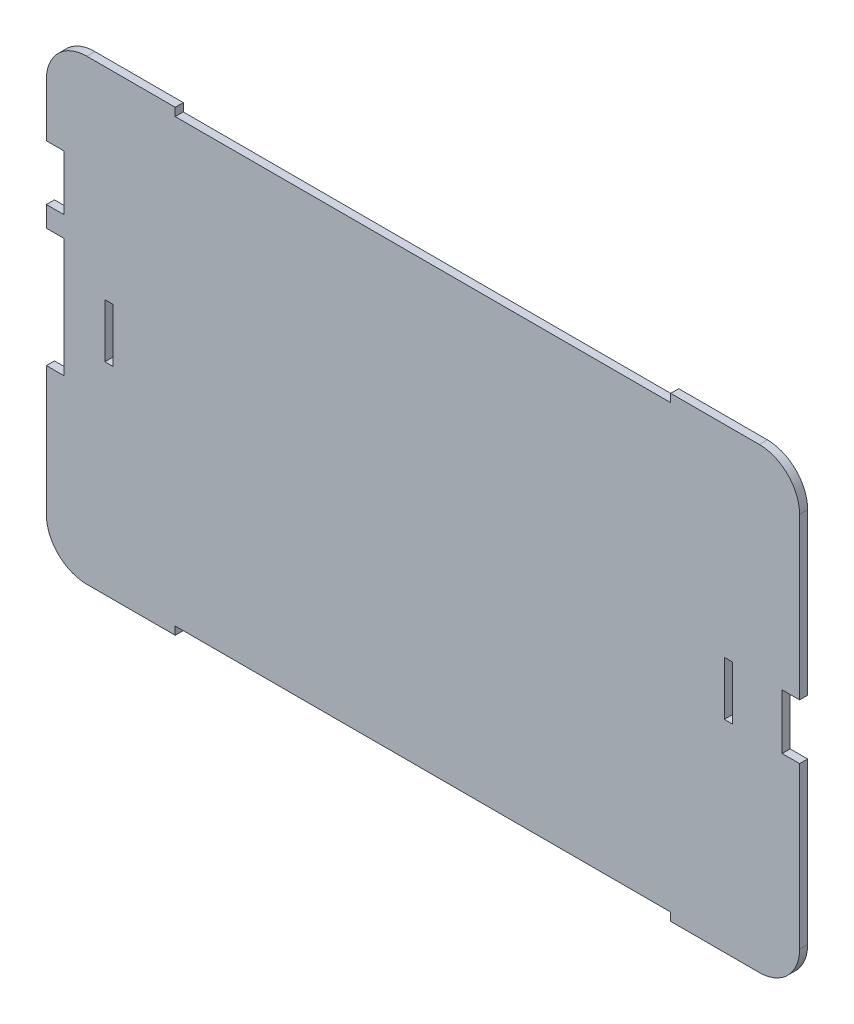
from build123d import *

# Parameters (mm, degrees)
SALIENTE_EXTRUIR2_DEPTH = 3
CROQUIS2_W              = 6.5
CROQUIS2_H              = 20.5
CROQUIS2_H_2            = 44.2
CROQUIS2_W_2            = 3
CROQUIS2_H_3            = 20
CORTAR_EXTRUIR1_DEPTH   = 3


with BuildPart() as part:
    # Croquis1 → Saliente-Extruir2 (new body)
    with BuildSketch(Plane.XY):
        with BuildLine():
            Line((-207.344846765, 3), (-174.444846765, 3))
            Line((-174.444846765, 3), (-174.444846765, 0))
            Line((-174.444846765, 0), (9.755153235, 0))
            Line((9.755153235, 0), (9.755153235, 3))
            Line((9.755153235, 3), (42.655153235, 3))
            ThreePointArc((42.655153235, 3), (53.261754953, -1.393398282), (57.655153235, -12))
            Line((57.655153235, -12), (57.655153235, -152))
            ThreePointArc((57.655153235, -152), (53.261754953, -162.606601718), (42.655153235, -167))
            Line((42.655153235, -167), (9.755153235, -167))
            Line((9.755153235, -167), (9.755153235, -164))
            Line((9.755153235, -164), (-174.444846765, -164))
            Line((-174.444846765, -164), (-174.444846765, -167))
            Line((-174.444846765, -167), (-207.344846765, -167))
            ThreePointArc((-207.344846765, -167), (-217.951448483, -162.606601718), (-222.344846765, -152))
            Line((-222.344846765, -152), (-222.344846765, -12))
            ThreePointArc((-222.344846765, -12), (-217.951448483, -1.393398282), (-207.344846765, 3))
        make_face()
    extrude(amount=SALIENTE_EXTRUIR2_DEPTH)

    # Croquis2 → Cortar-Extruir1 (cut)
    with BuildSketch(Plane.XY.offset(3)):
        with Locations((-219.094846765, -42)):
            Rectangle(CROQUIS2_W, CROQUIS2_H)
        with Locations((-219.094846765, -82)):
            Rectangle(CROQUIS2_W, CROQUIS2_H_2)
        with Locations((54.405153235, -82)):
            Rectangle(CROQUIS2_W, CROQUIS2_H)
        with Locations((-199.094846765, -82)):
            Rectangle(CROQUIS2_W_2, CROQUIS2_H_3)
        with Locations((31.155153235, -82)):
            Rectangle(CROQUIS2_W_2, CROQUIS2_H_3)
    extrude(amount=-CORTAR_EXTRUIR1_DEPTH, mode=Mode.SUBTRACT)


solid = part.part
